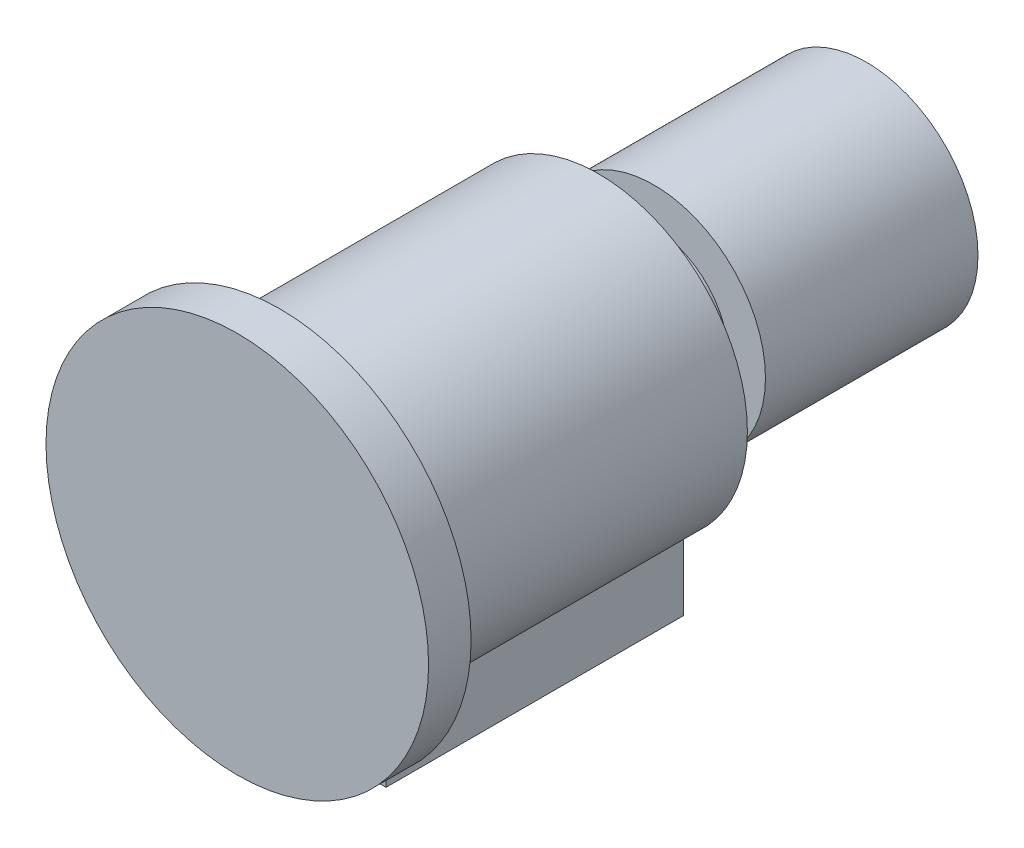
from build123d import *

# Parameters (mm, degrees)
CROQUIS2_R              = 90
SALIENTE_EXTRUIR2_DEPTH = 20
CROQUIS4_R              = 70
SALIENTE_EXTRUIR3_DEPTH = 150
CROQUIS5_R              = 35
SALIENTE_EXTRUIR4_DEPTH = 125
CROQUIS6_R              = 52.5
SALIENTE_EXTRUIR5_DEPTH = 100
CROQUIS7_W              = 90
CROQUIS7_H              = 140
SALIENTE_EXTRUIR7_DEPTH = 85


with BuildPart() as part:
    # Croquis2 → Saliente-Extruir2 (new body)
    with BuildSketch(Plane.XY):
        Circle(CROQUIS2_R)
    extrude(amount=SALIENTE_EXTRUIR2_DEPTH)

    # Croquis4 → Saliente-Extruir3 (add)
    with BuildSketch(Plane.XY):
        Circle(CROQUIS4_R)
    extrude(amount=-SALIENTE_EXTRUIR3_DEPTH)

    # Croquis5 → Saliente-Extruir4 (add)
    with BuildSketch(Plane.XY.offset(-150)):
        Circle(CROQUIS5_R)
    extrude(amount=-SALIENTE_EXTRUIR4_DEPTH)

    # Croquis7 → Saliente-Extruir7 (add)
    with BuildSketch(Plane(origin=(0, 0, 0), x_dir=(1, 0, 0), z_dir=(0, 1, 0))):
        with Locations((0, 75)):
            Rectangle(CROQUIS7_W, CROQUIS7_H)
    extrude(amount=-SALIENTE_EXTRUIR7_DEPTH)


with BuildPart() as body_2:
    # Croquis6 → Saliente-Extruir5 (new body)
    with BuildSketch(Plane.XY.offset(-276)):
        Circle(CROQUIS6_R)
    extrude(amount=SALIENTE_EXTRUIR5_DEPTH)


solid = Compound([part.part, body_2.part])
